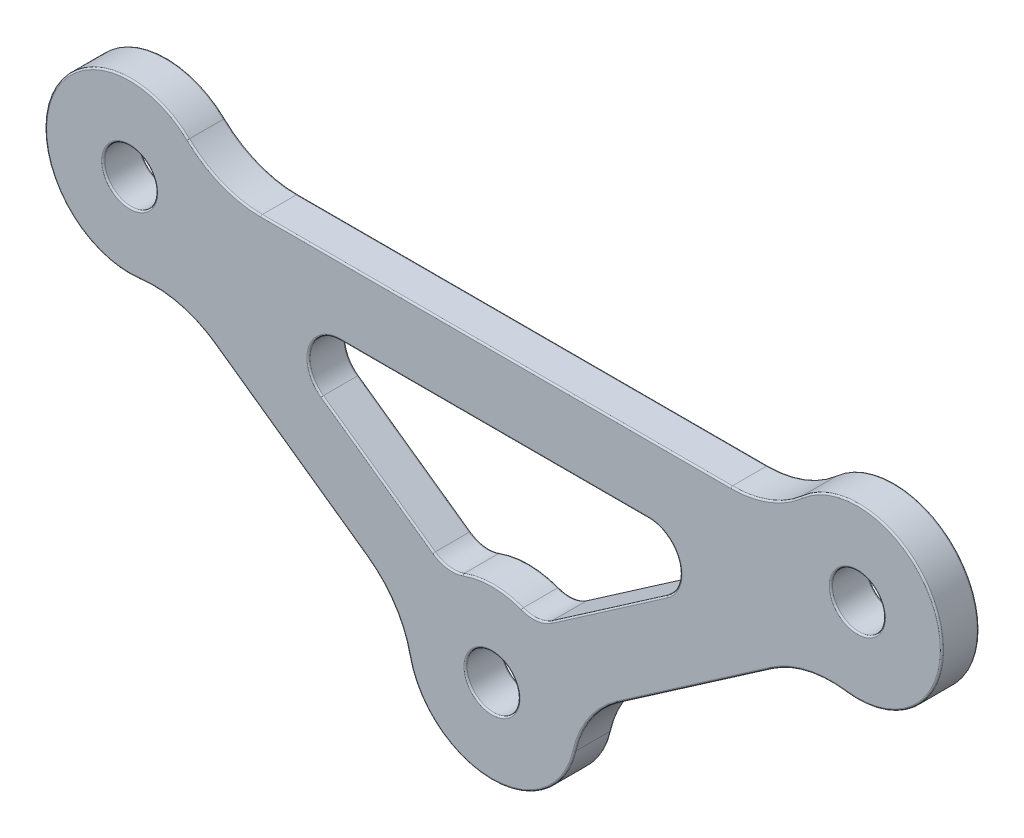
from build123d import *

# Parameters (mm, degrees)
SKETCH1_R             = 8
SKETCH1_R_2           = 2.5
BOSS_EXTRUDE1_DEPTH   = 3.5
BOSS_EXTRUDE1_2_DEPTH = 3.5
BOSS_EXTRUDE1_3_DEPTH = 3.5
SKETCH2_W             = 55
SKETCH2_H             = 6.5
EXTRUDE_THIN1_DEPTH   = 3.5
FILLET1_R             = 3
FILLET2_R             = 10
FILLET3_R             = 0.15


with BuildPart() as part:
    # Sketch1 → Boss-Extrude1 (new body)
    with BuildSketch(Plane.XY):
        with Locations((-86.790757919, 226.307344998)):
            Circle(SKETCH1_R)
        with Locations((-86.790757919, 226.307344998)):
            Circle(SKETCH1_R_2, mode=Mode.SUBTRACT)
    extrude(amount=-BOSS_EXTRUDE1_DEPTH)



with BuildPart() as body_2:
    # Sketch1 → Boss-Extrude1 2 (new body)
    with BuildSketch(Plane.XY):
        with Locations((-52.532670476, 202.009537592)):
            Circle(SKETCH1_R)
        with Locations((-52.532670476, 202.009537592)):
            Circle(SKETCH1_R_2, mode=Mode.SUBTRACT)
    extrude(amount=-BOSS_EXTRUDE1_2_DEPTH)


with BuildPart() as body_3:
    # Sketch1 → Boss-Extrude1 3 (new body)
    with BuildSketch(Plane.XY):
        with Locations((-17.983244178, 225.891269992)):
            Circle(SKETCH1_R)
        with Locations((-17.983244178, 225.891269992)):
            Circle(SKETCH1_R_2, mode=Mode.SUBTRACT)
    extrude(amount=-BOSS_EXTRUDE1_3_DEPTH)


with BuildPart() as part_1:
    add(part.part)

    add(body_2.part)  # Extrude-Thin1 merges body 2

    add(body_3.part)  # Extrude-Thin1 merges body 3
    # Sketch2 → Extrude-Thin1 (add)
    with BuildSketch(Plane.XY):
        with Locations((-52.387001049, 226.099307495)):
            Rectangle(SKETCH2_W, SKETCH2_H)
        Polygon((-45.74904695, 202.747746138), (-21.070885309, 219.806126424), (-24.766867704, 225.153061446), (-49.445029346, 208.09468116), align=None)
        Polygon((-55.54649549, 208.131576369), (-80.016557949, 225.487153088), (-83.776932905, 220.185306221), (-59.306870446, 202.829729502), align=None)
    extrude(amount=-EXTRUDE_THIN1_DEPTH)

    # Fillet1
    fillet1_edges = [part_1.edges().sort_by_distance(p)[0] for p in [
        (-28.099681924, 222.849307495, -1.75),
        (-48.367337516, 208.839618215, -1.75),
        (-56.615099658, 208.88949195, -1.75),
        (-76.297393358, 222.849307495, -1.75),
    ]]
    fillet(fillet1_edges, radius=FILLET1_R)

    # Fillet2
    fillet2_edges = [part_1.edges().sort_by_distance(p)[0] for p in [
        (-79.391672559, 229.349307495, -1.75),
        (-25.197256697, 229.349307495, -1.75),
        (-22.148577139, 219.061189368, -1.75),
        (-44.671355121, 203.492683193, -1.75),
        (-60.375474614, 203.587645084, -1.75),
        (-82.708328737, 219.42739064, -1.75),
    ]]
    fillet(fillet2_edges, radius=FILLET2_R)

    # Fillet3
    fillet3_edges = [part_1.edges().sort_by_distance(p)[0] for p in [
        (-52.298855759, 222.849307495, -3.5),
        (-52.298855759, 222.849307495, 0),
        (-41.472200397, 213.605770282, -3.5),
        (-41.472200397, 213.605770282, 0),
        (-63.326692521, 213.649739907, -3.5),
        (-63.326692521, 213.649739907, 0),
        (-52.484295829, 210.009391334, 0),
        (-52.484295829, 210.009391334, -3.5),
        (-34.85188115, 220.742770283, 0),
        (-34.85188115, 220.742770283, -3.5),
        (-69.740375392, 220.760071258, 0),
        (-69.740375392, 220.760071258, -3.5),
        (-48.276525417, 209.320006114, 0),
        (-48.276525417, 209.320006114, -3.5),
        (-56.700095574, 209.370942949, -3.5),
        (-56.700095574, 209.370942949, 0),
        (-52.581045124, 194.00968385, 0),
        (-52.581045124, 194.00968385, -3.5),
        (-33.40996613, 211.276936281, -3.5),
        (-33.40996613, 211.276936281, 0),
        (-10.326018961, 228.207927495, -3.5),
        (-10.326018961, 228.207927495, 0),
        (-71.541901676, 211.507517862, -3.5),
        (-71.541901676, 211.507517862, 0),
        (-94.392365386, 228.800448269, -3.5),
        (-94.392365386, 228.800448269, 0),
        (-52.160680502, 229.349307495, 0),
        (-52.160680502, 229.349307495, -3.5),
        (-43.262126204, 203.636440253, 0),
        (-43.262126204, 203.636440253, -3.5),
        (-22.781024171, 217.793670934, 0),
        (-22.781024171, 217.793670934, -3.5),
        (-61.782861959, 203.748434057, -3.5),
        (-61.782861959, 203.748434057, 0),
        (-82.091256613, 218.152316436, 0),
        (-82.091256613, 218.152316436, -3.5),
        (-26.384557642, 230.001396632, -3.5),
        (-26.384557642, 230.001396632, 0),
        (-78.095931795, 230.063421775, -3.5),
        (-78.095931795, 230.063421775, 0),
        (-20.483244178, 225.891269992, -3.5),
        (-20.483244178, 225.891269992, 0),
        (-89.290757919, 226.307344998, -3.5),
        (-89.290757919, 226.307344998, 0),
        (-55.032670476, 202.009537592, -3.5),
        (-55.032670476, 202.009537592, 0),
    ]]
    fillet(fillet3_edges, radius=FILLET3_R)


solid = part_1.part
